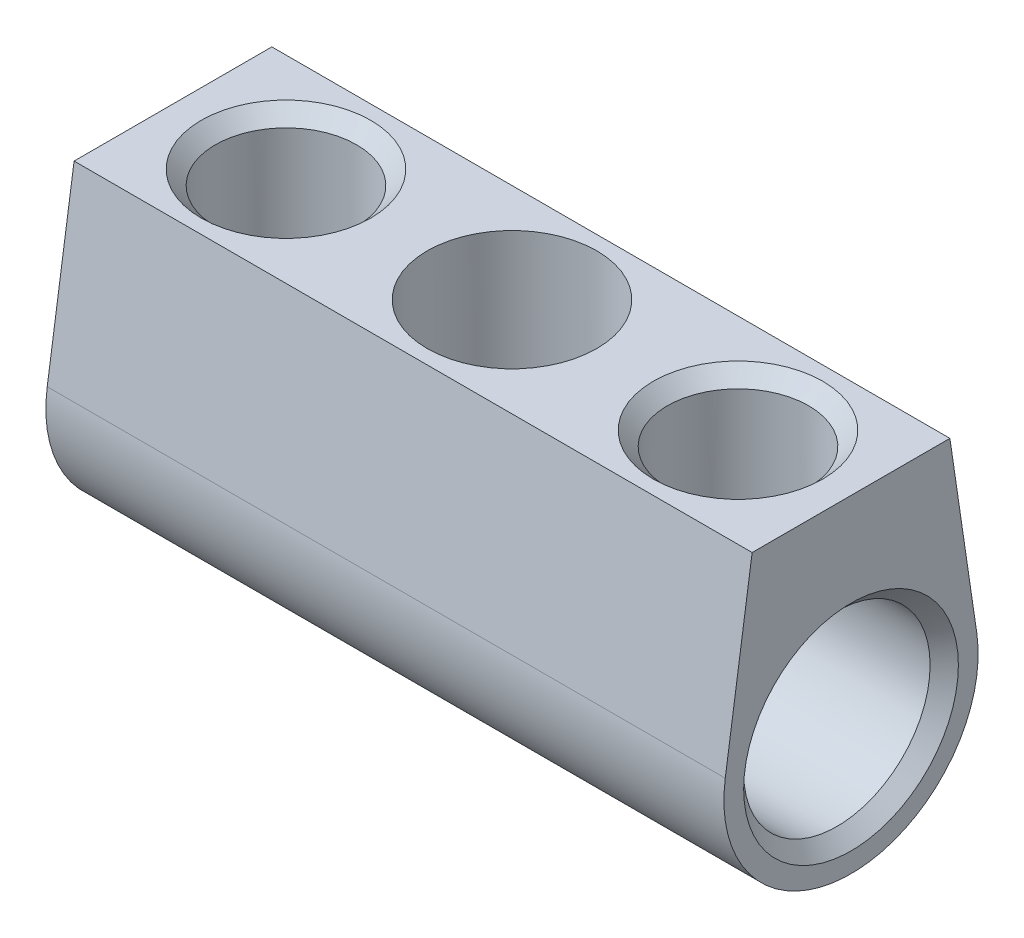
from build123d import *

# Parameters (mm, degrees)
SKETCH1_R               = 1.65
EXTRUDE1_DEPTH          = 6
SKETCH2_R               = 1.25
CUT_EXTRUDE1_DEPTH      = 4.55
SKETCH3_R               = 1.5
CUT_EXTRUDE2_DEPTH      = 4.5500001
CUT_EXTRUDE2_DEPTH_BACK = 3.25
CHAMFER1_SIZE           = 0.25


with BuildPart() as part:
    # Sketch1 → Extrude1 (new body, symmetric)
    with BuildSketch(Plane(origin=(0, 0, 0), x_dir=(0, 0, -1), z_dir=(1, 0, 0))):
        with BuildLine():
            Line((-2.225844711, 0.328808945), (-1.75, 3.55))
            Line((-1.75, 3.55), (1.75, 3.55))
            Line((1.75, 3.55), (2.225844711, 0.328808945))
            ThreePointArc((2.225844711, 0.328808945), (0, -2.25), (-2.225844711, 0.328808945))
        make_face()
        Circle(SKETCH1_R, mode=Mode.SUBTRACT)
    extrude(amount=EXTRUDE1_DEPTH, both=True)

    # Sketch2 → Cut-Extrude1 (cut, through all)
    with BuildSketch(Plane(origin=(0, 0, 0), x_dir=(1, 0, 0), z_dir=(0, 1, 0))):
        with Locations(Location((-4, 0, 0), (0, 0, 90))):  # turned: the seam where the file's is
            Circle(SKETCH2_R)
        with Locations(Location((4, 0, 0), (0, 0, 90))):  # turned: the seam where the file's is
            Circle(SKETCH2_R)
    extrude(amount=CUT_EXTRUDE1_DEPTH, mode=Mode.SUBTRACT)

    # Sketch3 → Cut-Extrude2 (cut, two sides)
    with BuildSketch(Plane(origin=(0, 0, 0), x_dir=(1, 0, 0), z_dir=(0, 1, 0))) as cut_extrude2_sk:
        with Locations(Location((0, 0, 0), (0, 0, 270))):  # turned: the seam where the file's is
            Circle(SKETCH3_R)
    extrude(amount=CUT_EXTRUDE2_DEPTH, mode=Mode.SUBTRACT)
    extrude(cut_extrude2_sk.sketch, amount=-CUT_EXTRUDE2_DEPTH_BACK, mode=Mode.SUBTRACT)

    # Chamfer1
    chamfer1_edges = [part.edges().sort_by_distance(p)[0] for p in [
        (-6, 0, 1.65),
        (6, 0, 1.65),
        (-4, 3.55, 1.25),
        (4, 3.55, 1.25),
    ]]
    chamfer(chamfer1_edges, length=CHAMFER1_SIZE)


solid = part.part
